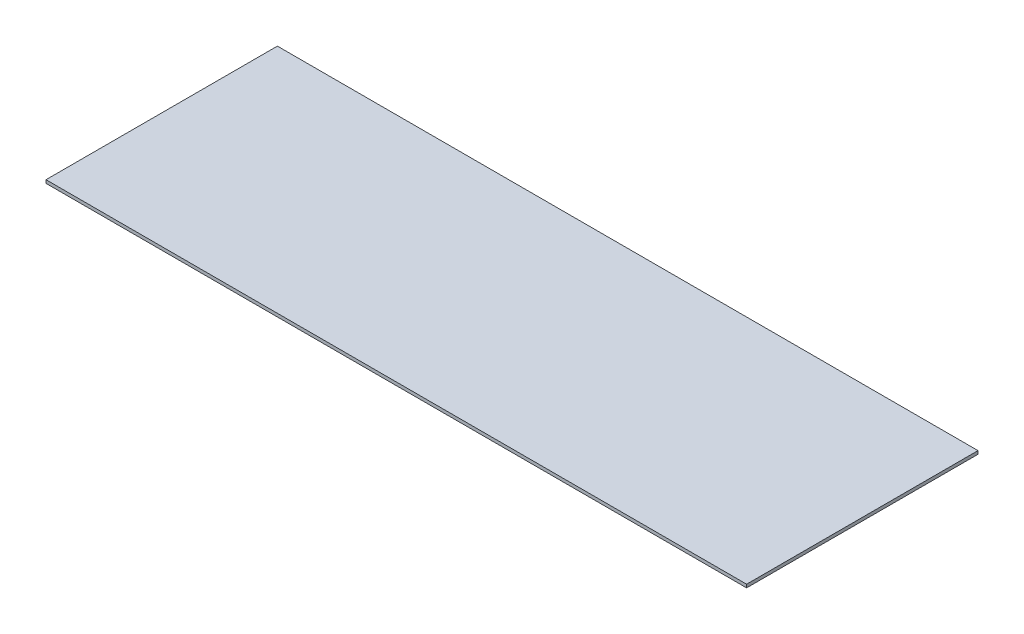
from build123d import *

# Parameters (mm, degrees)
SKETCH1_W           = 1090
SKETCH1_H           = 360
BOSS_EXTRUDE1_DEPTH = 5


with BuildPart() as part:
    # Sketch1 → Boss-Extrude1 (new body)
    with BuildSketch(Plane(origin=(0, 0, 0), x_dir=(1, 0, 0), z_dir=(0, 1, 0))):
        with Locations((-502.648714358, 151.739130435)):
            Rectangle(SKETCH1_W, SKETCH1_H)
    extrude(amount=BOSS_EXTRUDE1_DEPTH)


solid = part.part
